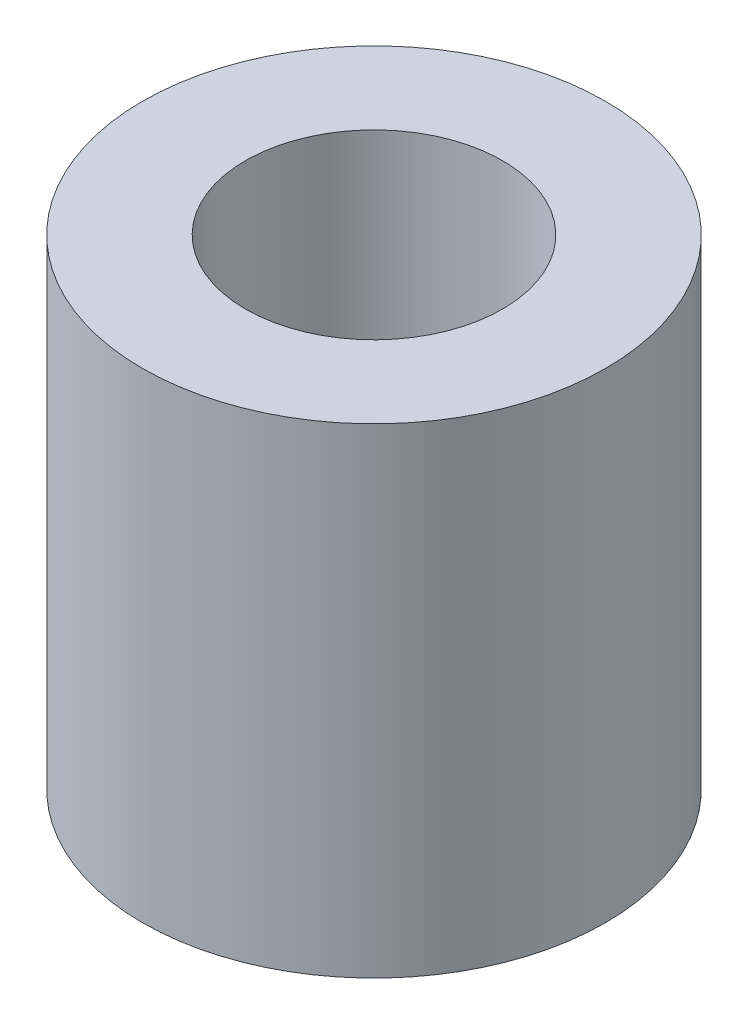
from build123d import *

# Parameters (mm, degrees)
ESBO_O1_R                = 3.375
ESBO_O1_R_2              = 1.875
RESSALTO_EXTRUS_O1_DEPTH = 7


with BuildPart() as part:
    # Esboço1 → Ressalto-extrusão1 (new body)
    with BuildSketch(Plane(origin=(0, 0, 0), x_dir=(1, 0, 0), z_dir=(0, 1, 0))):
        Circle(ESBO_O1_R)
        Circle(ESBO_O1_R_2, mode=Mode.SUBTRACT)
    extrude(amount=RESSALTO_EXTRUS_O1_DEPTH)


solid = part.part
